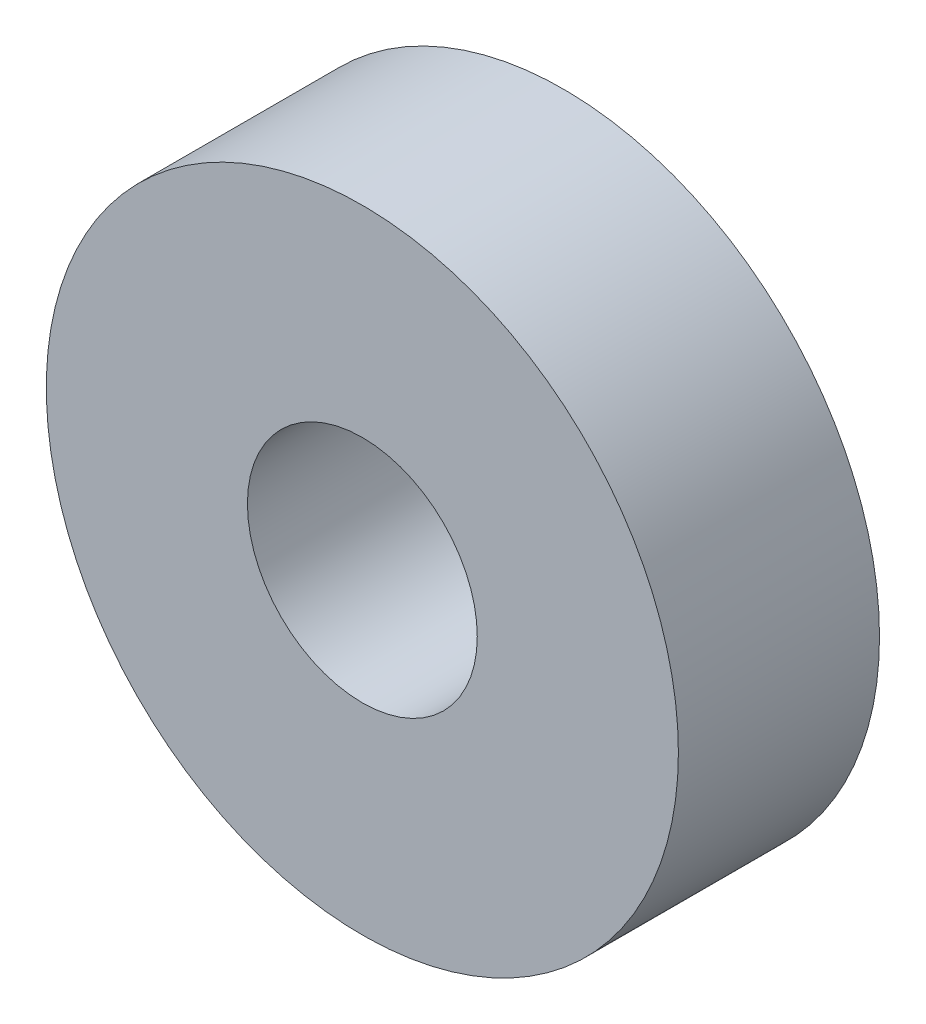
from build123d import *

# Parameters (mm, degrees)
SKETCH1_R      = 11
EXTRUDE1_DEPTH = 7
SKETCH2_R      = 4
EXTRUDE2_DEPTH = 8


with BuildPart() as part:
    # Sketch1 → Extrude1 (new body)
    with BuildSketch(Plane.XY):
        Circle(SKETCH1_R)
    extrude(amount=EXTRUDE1_DEPTH)

    # Sketch2 → Extrude2 (cut, through all)
    with BuildSketch(Plane.XY.offset(7)):
        Circle(SKETCH2_R)
    extrude(amount=-EXTRUDE2_DEPTH, mode=Mode.SUBTRACT)


solid = part.part
